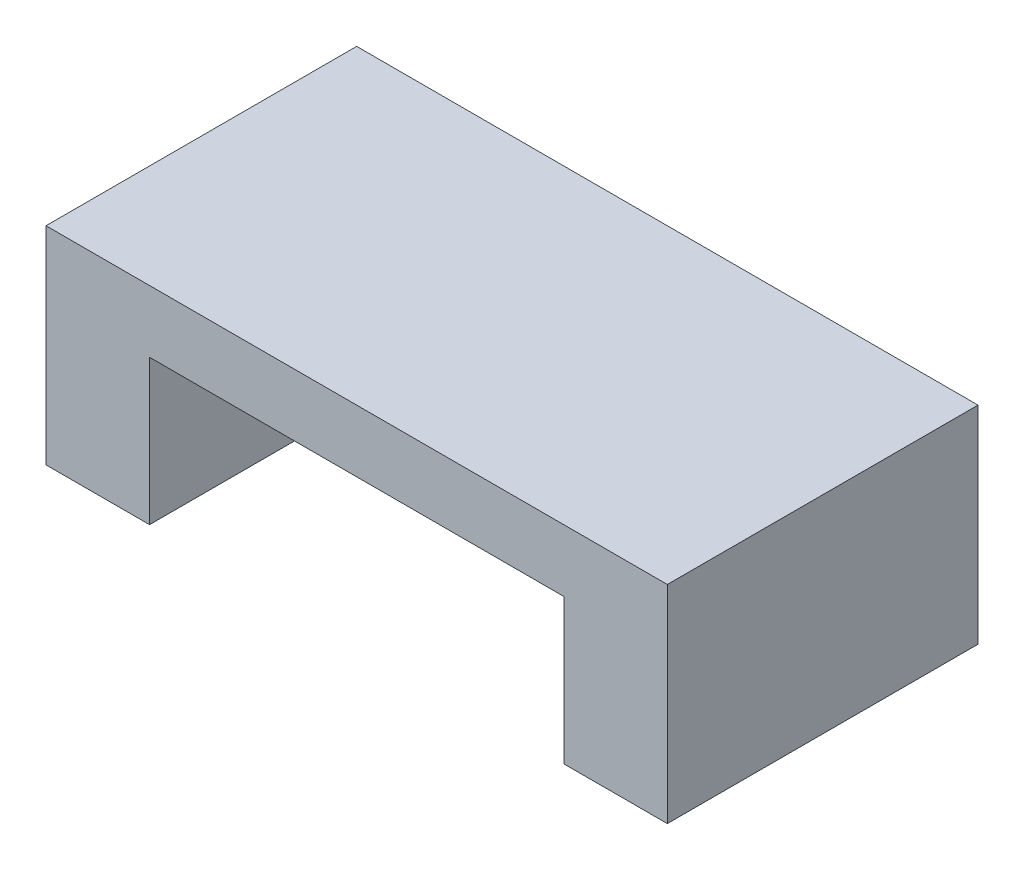
from build123d import *

# Parameters (mm, degrees)
SKETCH3_W           = 30
SKETCH3_H           = 15
BOSS_EXTRUDE1_DEPTH = 10
SKETCH4_W           = 20
SKETCH4_H           = 7
CUT_EXTRUDE1_DEPTH  = 16
SKETCH5_R           = 1.5
CUT_EXTRUDE2_DEPTH  = 5


with BuildPart() as part:
    # Sketch3 → Boss-Extrude1 (new body)
    with BuildSketch(Plane(origin=(0, 0, 0), x_dir=(1, 0, 0), z_dir=(0, 1, 0))):
        Rectangle(SKETCH3_W, SKETCH3_H)
    extrude(amount=BOSS_EXTRUDE1_DEPTH)

    # Sketch4 → Cut-Extrude1 (cut, through all)
    with BuildSketch(Plane.XY.offset(7.5)):
        with Locations((0, 3.5)):
            Rectangle(SKETCH4_W, SKETCH4_H)
    extrude(amount=-CUT_EXTRUDE1_DEPTH, mode=Mode.SUBTRACT)

    # Sketch5 → Cut-Extrude2 (cut)
    with BuildSketch(Plane.XZ):
        with Locations((12.5, 0)):
            Circle(SKETCH5_R)
        with Locations((-12.5, 0)):
            Circle(SKETCH5_R)
    extrude(amount=-CUT_EXTRUDE2_DEPTH, mode=Mode.SUBTRACT)


solid = part.part
